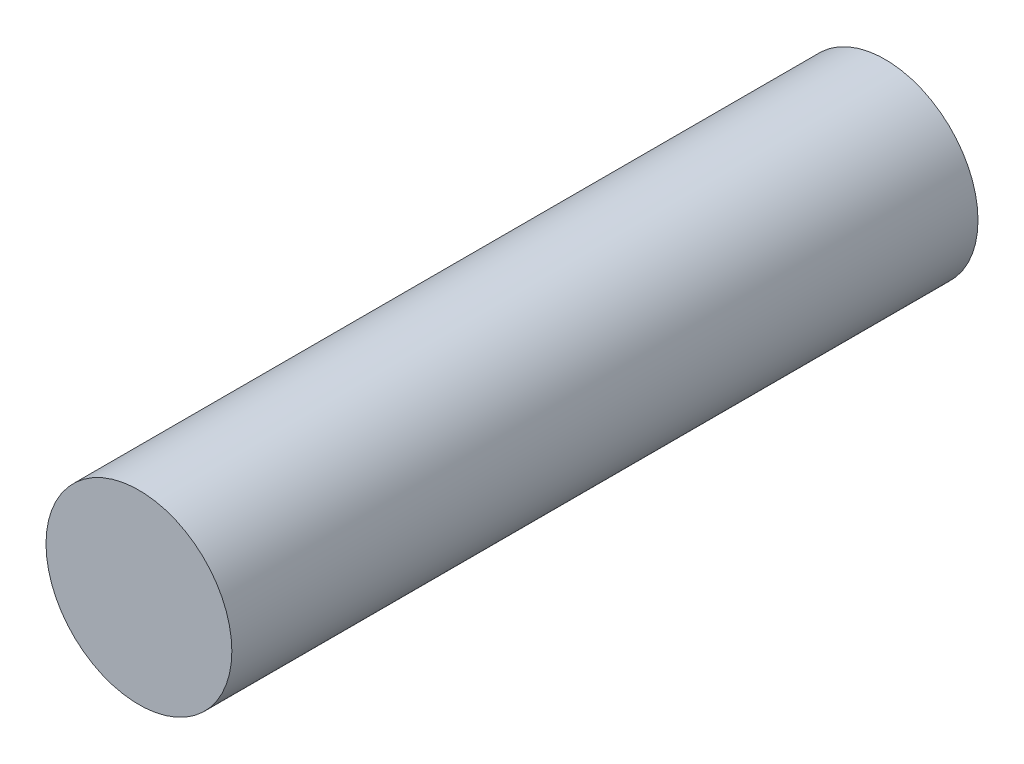
from build123d import *

# Parameters (mm, degrees)
SKETCH1_R           = 24.875
BOSS_EXTRUDE1_DEPTH = 199.75


with BuildPart() as part:
    # Sketch1 → Boss-Extrude1 (new body)
    with BuildSketch(Plane.XY):
        Circle(SKETCH1_R)
    extrude(amount=BOSS_EXTRUDE1_DEPTH)


solid = part.part
